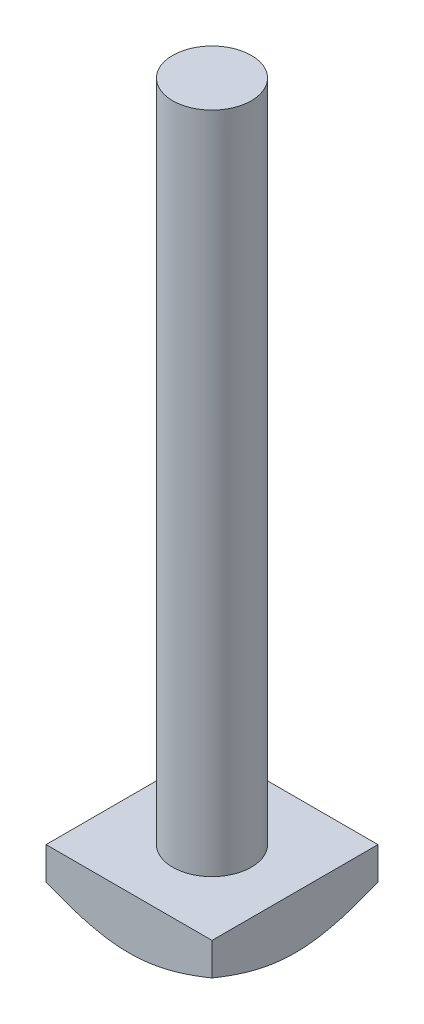
from build123d import *

# Parameters (mm, degrees)
SKETCH1_W           = 19
SKETCH1_H           = 19
BOSS_EXTRUDE1_DEPTH = 6
SKETCH2_R           = 4.5
BOSS_EXTRUDE2_DEPTH = 76
SKETCH13_OUTSIDE_W  = 59.042
SKETCH13_OUTSIDE_H  = 59.042
SKETCH13_OUTSIDE_R  = 9.5
CUT_EXTRUDE1_DEPTH  = 6
CUT_EXTRUDE1_DRAFT  = -60


with BuildPart() as part:
    # Sketch1 → Boss-Extrude1 (new body)
    with BuildSketch(Plane(origin=(0, 0, 0), x_dir=(1, 0, 0), z_dir=(0, 1, 0))):
        with Locations((9.5, 9.5)):
            Rectangle(SKETCH1_W, SKETCH1_H)
    extrude(amount=BOSS_EXTRUDE1_DEPTH)

    # Sketch2 → Boss-Extrude2 (add)
    with BuildSketch(Plane(origin=(0, 6, 0), x_dir=(1, 0, 0), z_dir=(0, 1, 0))):
        with Locations(Location((9.5, 9.5, 0), (0, 0, 90))):  # turned: the seam where the file's is
            Circle(SKETCH2_R)
    extrude(amount=BOSS_EXTRUDE2_DEPTH)


with BuildPart() as cut_extrude1_tool:
    # Sketch13 outside → Cut-Extrude1 (with draft: the straight prism first)
    with BuildSketch(Plane(origin=(0, 0, 0), x_dir=(-1, 0, 0), z_dir=(0, -1, 0))):
        with Locations((-9.5, 9.5)):
            Rectangle(SKETCH13_OUTSIDE_W, SKETCH13_OUTSIDE_H)
        with Locations((-9.5, 9.5)):
            Circle(SKETCH13_OUTSIDE_R, mode=Mode.SUBTRACT)
    extrude(amount=-CUT_EXTRUDE1_DEPTH)
    # Cut-Extrude1: the draft: its side faces are tilted about the plane it starts from
    cut_extrude1_sides = [cut_extrude1_tool.faces().sort_by_distance(p)[0] for p in [
        (9.5, 3, 20.021),
        (-20.021, 3, -9.5),
        (9.5, 3, -39.021),
        (39.021, 3, -9.5),
        (19, 3, -9.5),
    ]]
    draft(cut_extrude1_sides, Plane(origin=(0, 0, 0), x_dir=(-1, 0, 0), z_dir=(0, -1, 0)), CUT_EXTRUDE1_DRAFT)


with BuildPart() as part_1:
    add(part.part)

    # Cut-Extrude1: cut by cut_extrude1_tool
    add(cut_extrude1_tool.part, mode=Mode.SUBTRACT)


solid = part_1.part
